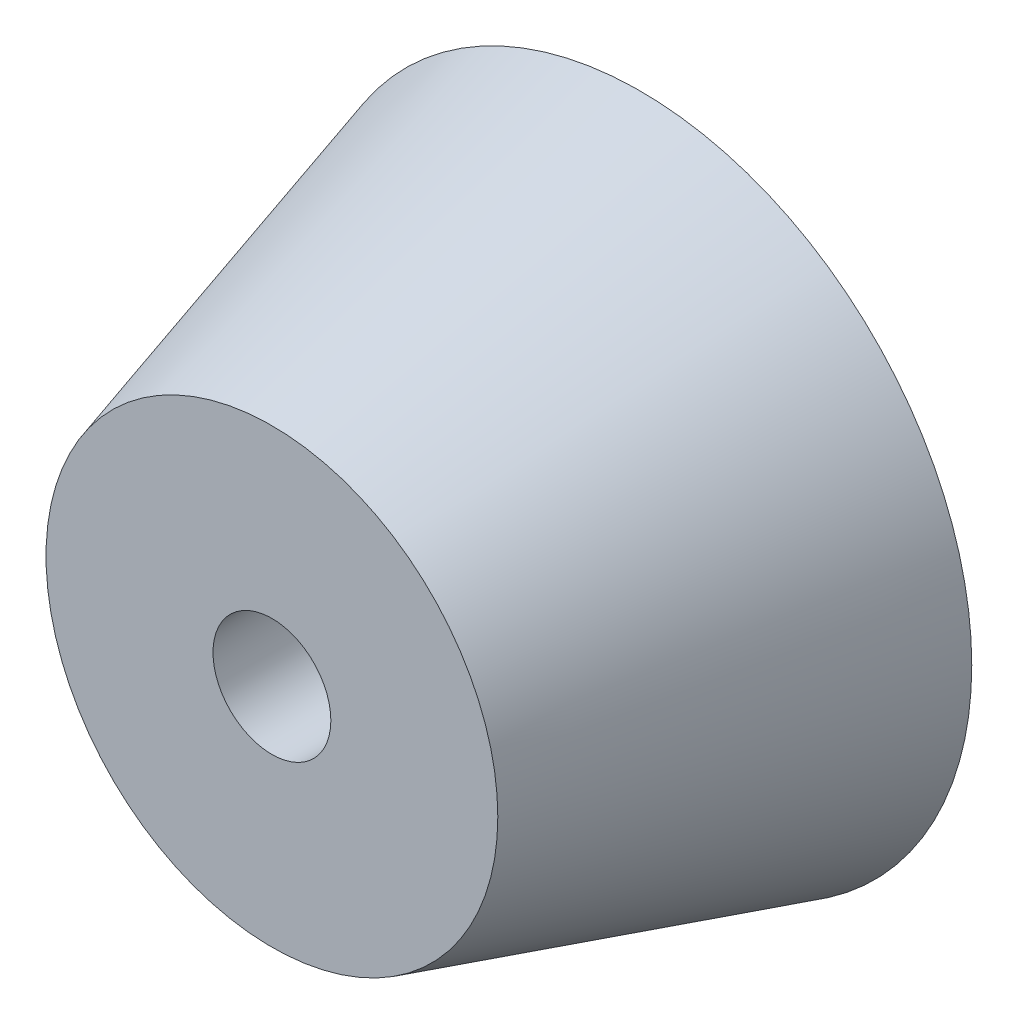
from build123d import *

# Parameters (mm, degrees)
ESBO_O1_R                = 9
RESSALTO_EXTRUS_O1_DEPTH = 10
RESSALTO_EXTRUS_O1_TAPER = 16
M3_CLEARANCE_HOLE1_D     = 3.2


with BuildPart() as part:
    # Esboço1 → Ressalto-extrusão1 (new body)
    with BuildSketch(Plane.XY.offset(-36.1)):
        with Locations((-45.57037618, -345.935502047)):
            Circle(ESBO_O1_R)
    extrude(amount=RESSALTO_EXTRUS_O1_DEPTH, taper=RESSALTO_EXTRUS_O1_TAPER)

    # M3 Clearance Hole1 (through all)
    with Locations(Plane.XY.offset(-26.1)):
        with Locations((-45.57037618, -345.935502047)):
            Hole(M3_CLEARANCE_HOLE1_D / 2)


solid = part.part
